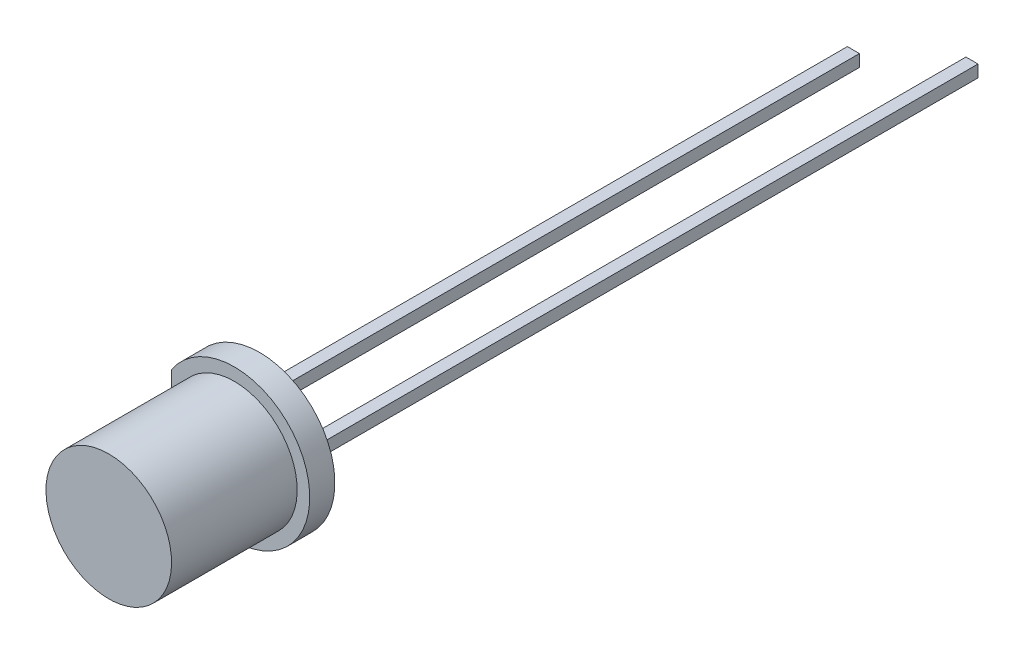
from build123d import *

# Parameters (mm, degrees)
ESBO_O1_R                  = 3
RESSALTO_EXTRUS_O1_DEPTH   = 1
ESBO_O3_W                  = 5
ESBO_O3_H                  = 2.5
CORTE_EXTRUS_O1_DEPTH      = 1
ESBO_O5_W                  = 0.48
ESBO_O5_H                  = 0.48
RESSALTO_EXTRUS_O2_DEPTH   = 25
RESSALTO_EXTRUS_O2_2_DEPTH = 25
ESBO_O6_W                  = 0.48
ESBO_O6_H                  = 0.48
RESSALTO_EXTRUS_O3_DEPTH   = 2
CORTE_EXTRUS_O2_DEPTH      = 0.24
RESSALTO_EXTRUS_O4_DEPTH   = 0.24
RESSALTO_EXTRUS_O4_2_DEPTH = 0.24
ESBO_O12_R                 = 0.2
CORTE_EXTRUS_O3_DEPTH      = 0.1


with BuildPart() as part:
    # Esboço1 → Ressalto-extrusão1 (new body)
    with BuildSketch(Plane.XY):
        Circle(ESBO_O1_R)
    extrude(amount=RESSALTO_EXTRUS_O1_DEPTH)

    # Esboço3 → Revolução1 (revolve)
    with BuildSketch(Plane(origin=(0, 0, 0), x_dir=(0, 0, -1), z_dir=(1, 0, 0))):
        with Locations((-3.5, 1.25)):
            Rectangle(ESBO_O3_W, ESBO_O3_H)
    revolve(axis=Axis((0, 0, 1), (0, 0, 1)))

    # Esboço4 → Corte-extrusão1 (cut)
    with BuildSketch(Plane(origin=(0, 0, 0), x_dir=(-1, 0, 0), z_dir=(0, 0, -1))):
        with BuildLine():
            Line((2.5, 1.658312395), (2.5, -1.658312395))
            ThreePointArc((2.5, -1.658312395), (3, 0), (2.5, 1.658312395))
        make_face()
    extrude(amount=-CORTE_EXTRUS_O1_DEPTH, mode=Mode.SUBTRACT)

    # Esboço7 → Corte-extrusão2 (cut, symmetric)
    with BuildSketch(Plane(origin=(0, 0, 0), x_dir=(1, 0, 0), z_dir=(0, 1, 0))):
        Polygon((-1.6, 0), (-1.6, -3.5), (-1.3, -4), (1.2, -4), (0.02, -2), (-1.12, -2), (-1.12, 0), align=None)
        Polygon((1.6, 0), (1.6, -4), (1.4, -4), (0.22, -2), (1.12, -2), (1.12, 0), align=None)
    extrude(amount=CORTE_EXTRUS_O2_DEPTH, both=True, mode=Mode.SUBTRACT)


with BuildPart() as body_2:
    # Esboço5 → Ressalto-extrusão2 (new body)
    with BuildSketch(Plane(origin=(0, 0, 0), x_dir=(-1, 0, 0), z_dir=(0, 0, -1))):
        with Locations((-1.36, 0)):
            Rectangle(ESBO_O5_W, ESBO_O5_H)
    extrude(amount=RESSALTO_EXTRUS_O2_DEPTH)


with BuildPart() as body_3:
    # Esboço5 → Ressalto-extrus_o2 2 (new body)
    with BuildSketch(Plane(origin=(0, 0, 0), x_dir=(-1, 0, 0), z_dir=(0, 0, -1))):
        with Locations((1.36, 0)):
            Rectangle(ESBO_O5_W, ESBO_O5_H)
    extrude(amount=RESSALTO_EXTRUS_O2_2_DEPTH)


with BuildPart() as body_4:
    # Esboço6 → Ressalto-extrusão3 (new body)
    with BuildSketch(Plane(origin=(0, 0, -25), x_dir=(-1, 0, 0), z_dir=(0, 0, -1))):
        with Locations((-1.36, 0)):
            Rectangle(ESBO_O6_W, ESBO_O6_H)
    extrude(amount=RESSALTO_EXTRUS_O3_DEPTH)


with BuildPart() as body_5:
    # Esboço8 → Ressalto-extrusão4 (new body, symmetric)
    with BuildSketch(Plane(origin=(0, 0, 0), x_dir=(1, 0, 0), z_dir=(0, 1, 0))):
        Polygon((-1.3, -4), (1.2, -4), (0.02, -2), (-1.12, -2), (-1.12, 0), (-1.6, 0), (-1.6, -3.5), align=None)
    extrude(amount=RESSALTO_EXTRUS_O4_DEPTH, both=True)

    # Combinar2: union body 3
    add(body_3.part)

    # Esboço10 → Corte-Revolução1 (revolve, cut)
    with BuildSketch(Plane(origin=(0, 0, 0), x_dir=(1, 0, 0), z_dir=(0, 1, 0))):
        with BuildLine():
            Line((-0.05, -4), (-0.05, -3.7))
            ThreePointArc((-0.05, -3.7), (-0.341547595, -3.780754009), (-0.55, -4))
            Line((-0.55, -4), (-0.05, -4))
        make_face()
    revolve(axis=Axis((-0.05, 0, 4), (0, 0, -1)), mode=Mode.SUBTRACT)


with BuildPart() as body_6:
    # Esboço8 → Ressalto-extrus_o4 2 (new body, symmetric)
    with BuildSketch(Plane(origin=(0, 0, 0), x_dir=(1, 0, 0), z_dir=(0, 1, 0))):
        Polygon((0.22, -2), (1.4, -4), (1.6, -4), (1.6, 0), (1.12, 0), (1.12, -2), align=None)
    extrude(amount=RESSALTO_EXTRUS_O4_2_DEPTH, both=True)

    # Combinar1: union body 4, body 2
    add(body_4.part)
    add(body_2.part)


with BuildPart() as body_4_2:
    # Esboço11 → Revolução2 (revolve)
    with BuildSketch(Plane(origin=(0, 0, 0), x_dir=(1, 0, 0), z_dir=(0, 1, 0))):
        with BuildLine():
            Line((-0.55, -4), (-0.05, -4))
            Line((-0.05, -4), (-0.05, -3.7))
            ThreePointArc((-0.05, -3.7), (-0.341547595, -3.780754009), (-0.55, -4))
        make_face()
    revolve(axis=Axis((-0.05, 0, 4), (0, 0, -1)))

    # Combinar3: union body 5
    add(body_5.part)

    # Esboço12 → Corte-extrusão3 (cut)
    with BuildSketch(Plane.XY.offset(4)):
        with Locations((-0.05, 0)):
            Circle(ESBO_O12_R)
    extrude(amount=-CORTE_EXTRUS_O3_DEPTH, mode=Mode.SUBTRACT)


solid = Compound([part.part, body_6.part, body_4_2.part])
